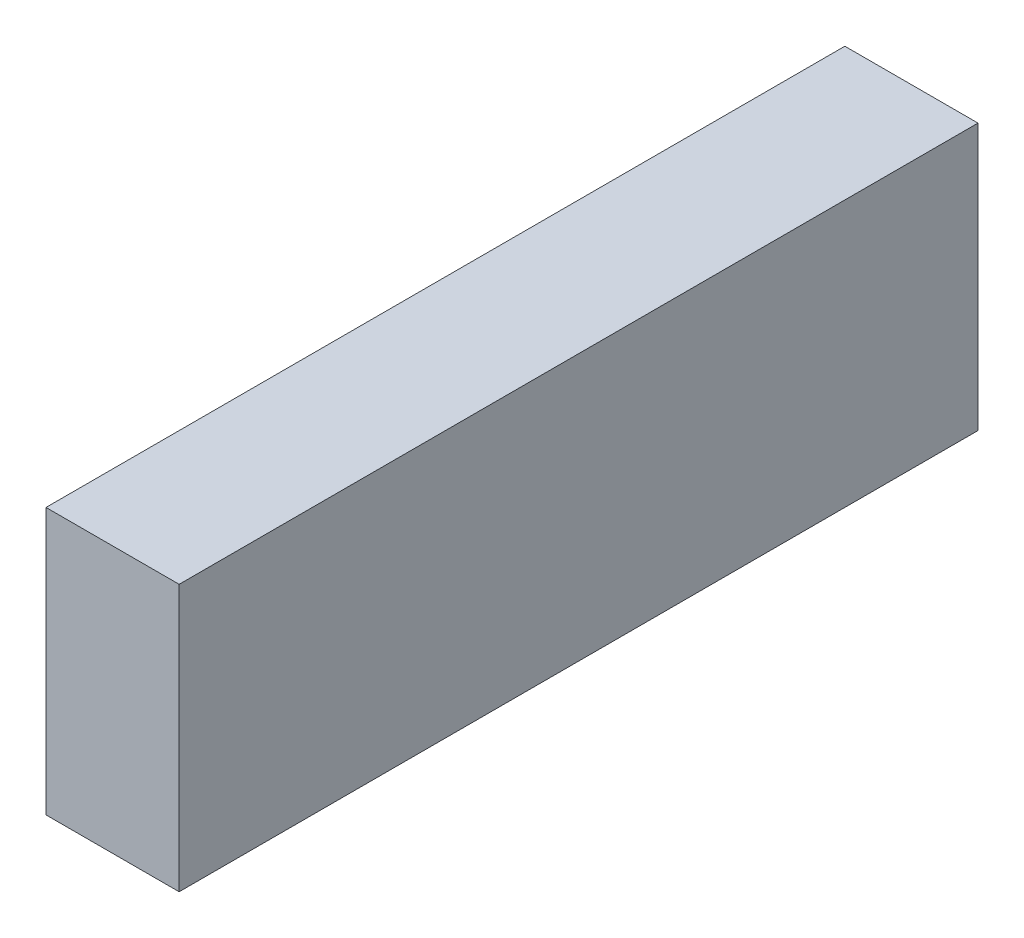
from build123d import *

# Parameters (mm, degrees)
SKETCH_1_W      = 50
SKETCH_1_H      = 300
EXTRUDE_1_DEPTH = 100


with BuildPart() as part:
    # 草图1 → 凸台-拉伸1 (new body)
    with BuildSketch(Plane(origin=(0, 0, 0), x_dir=(1, 0, 0), z_dir=(0, 1, 0))):
        Rectangle(SKETCH_1_W, SKETCH_1_H)
    extrude(amount=EXTRUDE_1_DEPTH)


solid = part.part
